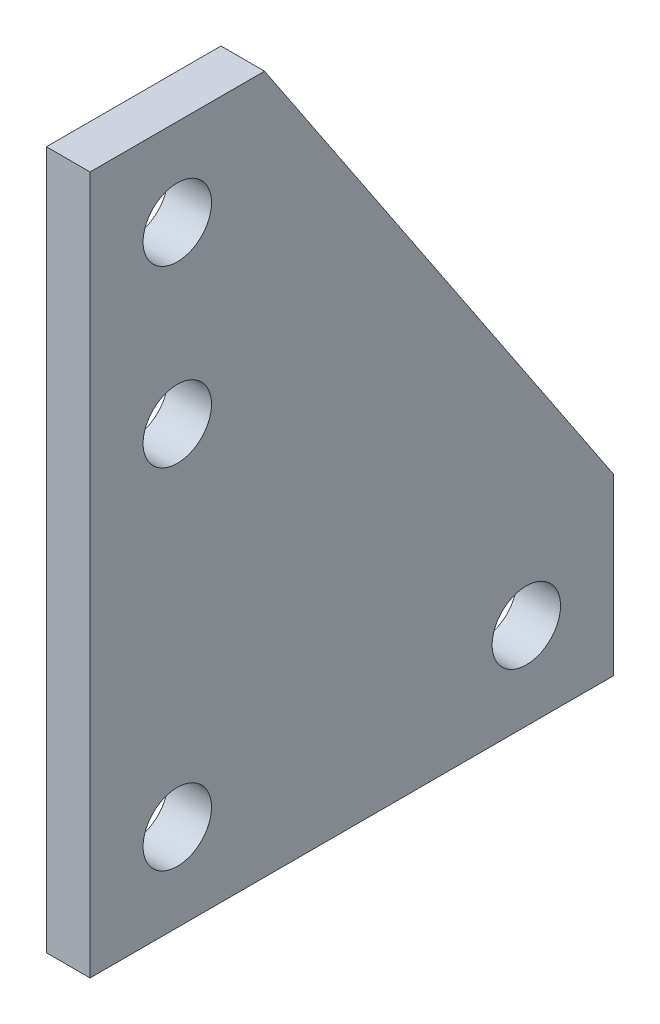
from build123d import *

# Parameters (mm, degrees)
SKETCH3_R           = 2.4892
BOSS_EXTRUDE1_DEPTH = 3.175


with BuildPart() as part:
    # Sketch3 → Boss-Extrude1 (new body)
    with BuildSketch(Plane(origin=(0, 0, 0), x_dir=(0, 0, -1), z_dir=(1, 0, 0))):
        Polygon((0, 0), (38.1, 0), (38.1, 12.7), (12.7, 50.8), (0, 50.8), align=None)
        with Locations((6.35, 44.45)):
            Circle(SKETCH3_R, mode=Mode.SUBTRACT)
        with Locations((6.35, 31.75)):
            Circle(SKETCH3_R, mode=Mode.SUBTRACT)
        with Locations((6.35, 6.35)):
            Circle(SKETCH3_R, mode=Mode.SUBTRACT)
        with Locations((31.75, 6.35)):
            Circle(SKETCH3_R, mode=Mode.SUBTRACT)
    extrude(amount=BOSS_EXTRUDE1_DEPTH)


solid = part.part
